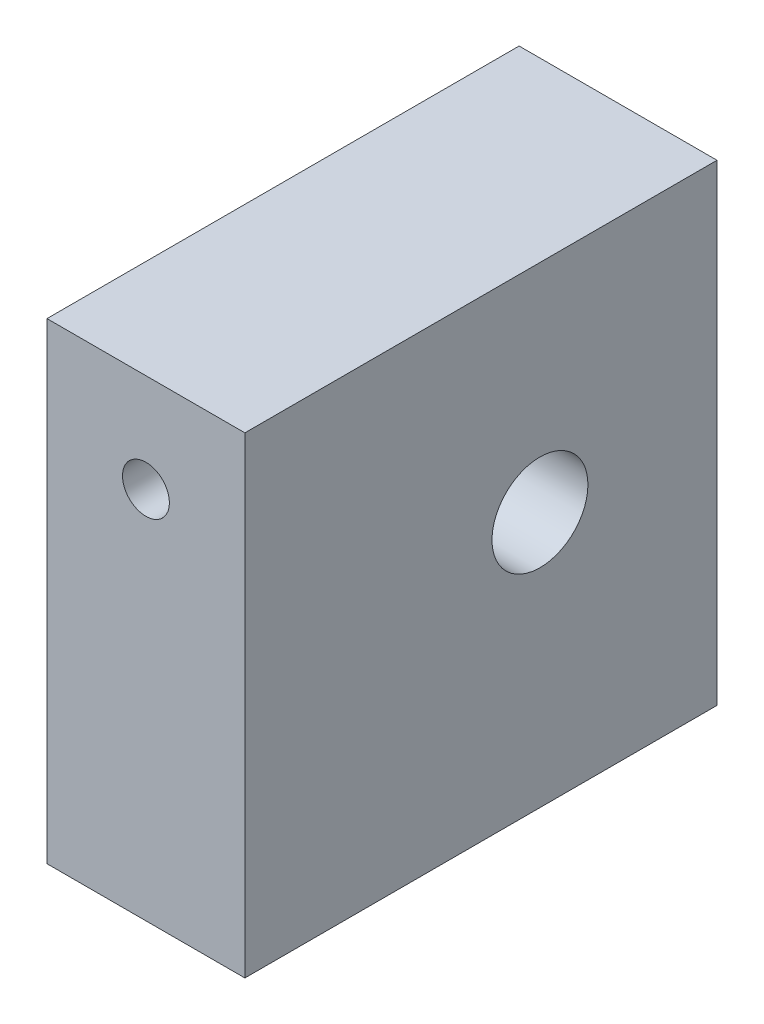
from build123d import *

# Parameters (mm, degrees)
SKETCH1_W                     = 12
SKETCH1_H                     = 12
BOSS_EXTRUDE1_DEPTH           = 5.03
TAP_DRILL_FOR_0_80_TAP1_D     = 1.19126
TAP_DRILL_FOR_0_80_TAP1_DEPTH = 4
TAP_DRILL_FOR_0_80_TAP1_TIP   = 0.357890611
F_2_CLEARANCE_HOLE1_D         = 2.4384


with BuildPart() as part:
    # Sketch1 → Boss-Extrude1 (new body)
    with BuildSketch(Plane(origin=(0, 0, 0), x_dir=(0, 0, -1), z_dir=(1, 0, 0))):
        with Locations((6, 6)):
            Rectangle(SKETCH1_W, SKETCH1_H)
    extrude(amount=BOSS_EXTRUDE1_DEPTH)

    # Tap Drill for #0-80 Tap1
    with Locations(Plane.XY):
        with Locations((2.515, 9.5)):
            Hole(TAP_DRILL_FOR_0_80_TAP1_D / 2, depth=TAP_DRILL_FOR_0_80_TAP1_DEPTH)
            with Locations((0, 0, -(TAP_DRILL_FOR_0_80_TAP1_DEPTH + TAP_DRILL_FOR_0_80_TAP1_TIP / 2))):  # 118° drill point
                Cone(0, TAP_DRILL_FOR_0_80_TAP1_D / 2, TAP_DRILL_FOR_0_80_TAP1_TIP, mode=Mode.SUBTRACT)

    # #2 Clearance Hole1 (through all)
    with Locations(Plane(origin=(5.03, 0, 0), x_dir=(0, 0, -1), z_dir=(1, 0, 0))):
        with Locations((7.5, 6.5)):
            Hole(F_2_CLEARANCE_HOLE1_D / 2)


solid = part.part
